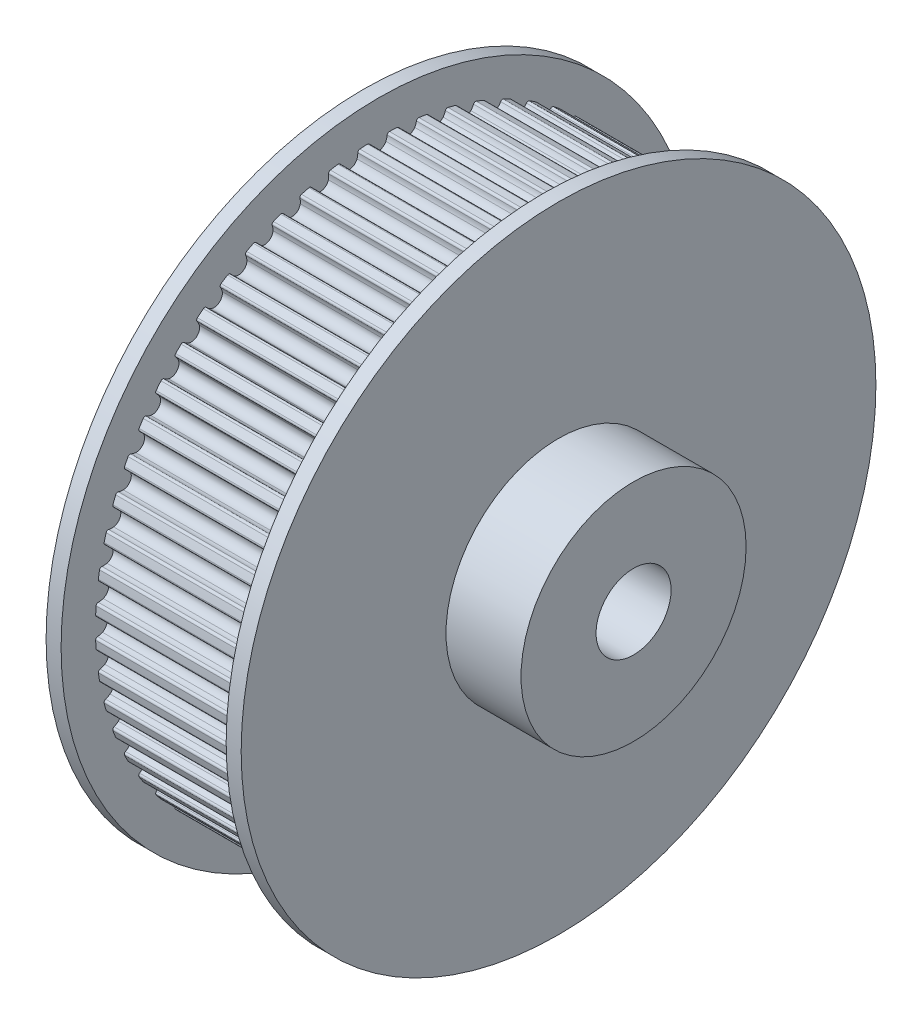
from build123d import *

# Parameters (mm, degrees)
SKETCH1_R           = 5
BOSS_EXTRUDE1_DEPTH = 11
SKETCH2_R           = 5
SKETCH2_R_2         = 2.5
BOSS_EXTRUDE2_DEPTH = 11
SKETCH3_R           = 21.15
SKETCH3_R_2         = 2.5
BOSS_EXTRUDE3_DEPTH = 1
SKETCH4_R           = 21.15
SKETCH4_R_2         = 2.5
BOSS_EXTRUDE4_DEPTH = 1
SKETCH5_R           = 7.5
SKETCH5_R_2         = 2.5
BOSS_EXTRUDE5_DEPTH = 5


with BuildPart() as part:
    # Sketch1 → Boss-Extrude1 (new body)
    with BuildSketch(Plane(origin=(0, 0, 0), x_dir=(0, 0, -1), z_dir=(1, 0, 0))):
        with BuildLine():
            ThreePointArc((37.94444628, 18.368252698), (37.907163031, 18.467222058), (37.813847158, 18.51699276))
            ThreePointArc((37.813847158, 18.51699276), (37.64832341, 18.545935993), (37.489982797, 18.60218608))
            ThreePointArc((37.489982797, 18.60218608), (37.266075143, 18.806812404), (37.183186342, 19.098593171))
            ThreePointArc((37.183186342, 19.098593171), (37.266075143, 19.390373938), (37.489982797, 19.595000262))
            ThreePointArc((37.489982797, 19.595000262), (37.64832341, 19.651250349), (37.813847158, 19.680193582))
            ThreePointArc((37.813847158, 19.680193582), (37.907163031, 19.729964284), (37.94444628, 19.828933644))
            ThreePointArc((37.94444628, 19.828933644), (37.932747007, 20.085649348), (37.917548092, 20.342181644))
            ThreePointArc((37.917548092, 20.342181644), (37.870123969, 20.436711679), (37.772116836, 20.476455567))
            ThreePointArc((37.772116836, 20.476455567), (37.604474452, 20.487938303), (37.44112151, 20.527329145))
            ThreePointArc((37.44112151, 20.527329145), (37.197051171, 20.707429781), (37.084117048, 20.988947904))
            ThreePointArc((37.084117048, 20.988947904), (37.136052381, 21.287794505), (37.337344169, 21.514704587))
            ThreePointArc((37.337344169, 21.514704587), (37.488937641, 21.587197631), (37.650529241, 21.633284253))
            ThreePointArc((37.650529241, 21.633284253), (37.738131465, 21.692536471), (37.764865358, 21.794860827))
            ThreePointArc((37.764865358, 21.794860827), (37.726396076, 22.048947309), (37.684465496, 22.302485575))
            ThreePointArc((37.684465496, 22.302485575), (37.627420088, 22.391540593), (37.52579548, 22.420822225))
            ThreePointArc((37.52579548, 22.420822225), (37.357871186, 22.414718657), (37.191295645, 22.43681868))
            ThreePointArc((37.191295645, 22.43681868), (36.929736706, 22.590420408), (36.787994592, 22.858591515))
            ThreePointArc((36.787994592, 22.858591515), (36.808407441, 23.161229723), (36.98487797, 23.40793749))
            ThreePointArc((36.98487797, 23.40793749), (37.12806341, 23.495879241), (37.283952431, 23.558604318))
            ThreePointArc((37.283952431, 23.558604318), (37.364881217, 23.626688872), (37.380772851, 23.731247137))
            ThreePointArc((37.380772851, 23.731247137), (37.315955039, 23.979920572), (37.247752194, 24.227686989))
            ThreePointArc((37.247752194, 24.227686989), (37.181710502, 24.310291286), (37.07758184, 24.328789846))
            ThreePointArc((37.07758184, 24.328789846), (36.91121545, 24.305166846), (36.743242345, 24.309733917))
            ThreePointArc((36.743242345, 24.309733917), (36.467060501, 24.435153845), (36.298063351, 24.687039797))
            ThreePointArc((36.298063351, 24.687039797), (36.28673007, 24.990153845), (36.436445891, 25.253956314))
            ThreePointArc((36.436445891, 25.253956314), (36.56965453, 25.356383266), (36.718133018, 25.435059568))
            ThreePointArc((36.718133018, 25.435059568), (36.791501695, 25.511230509), (36.796376958, 25.616877121))
            ThreePointArc((36.796376958, 25.616877121), (36.705920773, 25.85741299), (36.612192907, 26.096692979))
            ThreePointArc((36.612192907, 26.096692979), (36.537878498, 26.171941524), (36.432386638, 26.179454338))
            ThreePointArc((36.432386638, 26.179454338), (36.269400896, 26.138570724), (36.101870577, 26.125554806))
            ThreePointArc((36.101870577, 26.125554806), (35.814091733, 26.221418807), (35.619691116, 26.454259889))
            ThreePointArc((35.619691116, 26.454259889), (35.576735874, 26.754528796), (35.698056669, 27.032535692))
            ThreePointArc((35.698056669, 27.032535692), (35.819829046, 27.148325632), (35.959270241, 27.242091166))
            ThreePointArc((35.959270241, 27.242091166), (36.024274964, 27.325513949), (36.018080442, 27.431091422))
            ThreePointArc((36.018080442, 27.431091422), (35.902976941, 27.660854365), (35.784750956, 27.889026323))
            ThreePointArc((35.784750956, 27.889026323), (35.702978035, 27.956094678), (35.597278768, 27.952539434))
            ThreePointArc((35.597278768, 27.952539434), (35.43945938, 27.894843135), (35.274207343, 27.864386832))
            ThreePointArc((35.274207343, 27.864386832), (34.977984466, 27.9296446), (34.760310274, 28.140889757))
            ThreePointArc((34.760310274, 28.140889757), (34.686203698, 28.435023714), (34.777800252, 28.724189135))
            ThreePointArc((34.777800252, 28.724189135), (34.886802202, 28.852073446), (35.015678356, 28.959900895))
            ThreePointArc((35.015678356, 28.959900895), (35.071606922, 29.049661524), (35.054410483, 29.154013129))
            ThreePointArc((35.054410483, 29.154013129), (34.915920763, 29.370485814), (34.774491969, 29.585049841))
            ThreePointArc((34.774491969, 29.585049841), (34.686156456, 29.643203191), (34.581407845, 29.628618841))
            ThreePointArc((34.581407845, 29.628618841), (34.430483914, 29.554741991), (34.269320695, 29.507178989))
            ThreePointArc((34.269320695, 29.507178989), (33.967899264, 29.541115546), (33.729336383, 29.728450331))
            ThreePointArc((33.729336383, 29.728450331), (33.6248904, 30.013226745), (33.685759161, 30.310382535))
            ThreePointArc((33.685759161, 30.310382535), (33.780796437, 30.448960088), (33.897695556, 30.569668074))
            ThreePointArc((33.897695556, 30.569668074), (33.943935198, 30.664783112), (33.915925251, 30.76676555))
            ThreePointArc((33.915925251, 30.76676555), (33.755566635, 30.967576257), (33.592484554, 31.166181546))
            ThreePointArc((33.592484554, 31.166181546), (33.498554273, 31.21478275), (33.395903965, 31.189329083))
            ThreePointArc((33.395903965, 31.189329083), (33.253529044, 31.100081092), (33.098220382, 31.035932502))
            ThreePointArc((33.098220382, 31.035932502), (32.794902832, 31.038176032), (32.538065007, 31.199547965))
            ThreePointArc((32.538065007, 31.199547965), (32.404423949, 31.471846767), (32.433898027, 31.773737224))
            ThreePointArc((32.433898027, 31.773737224), (32.51392938, 31.921489735), (32.617570693, 32.053755756))
            ThreePointArc((32.617570693, 32.053755756), (32.653614801, 32.153183102), (32.615098227, 32.251679033))
            ThreePointArc((32.615098227, 32.251679033), (32.434627638, 32.434627638), (32.251679033, 32.615098227))
            ThreePointArc((32.251679033, 32.615098227), (32.153183102, 32.653614801), (32.053755756, 32.617570693))
            ThreePointArc((32.053755756, 32.617570693), (31.921489735, 32.51392938), (31.773737224, 32.433898027))
            ThreePointArc((31.773737224, 32.433898027), (31.471846767, 32.404423949), (31.199547965, 32.538065007))
            ThreePointArc((31.199547965, 32.538065007), (31.038176032, 32.794902832), (31.035932502, 33.098220382))
            ThreePointArc((31.035932502, 33.098220382), (31.100081092, 33.253529044), (31.189329083, 33.395903965))
            ThreePointArc((31.189329083, 33.395903965), (31.21478275, 33.498554273), (31.166181546, 33.592484554))
            ThreePointArc((31.166181546, 33.592484554), (30.967576257, 33.755566635), (30.76676555, 33.915925251))
            ThreePointArc((30.76676555, 33.915925251), (30.664783112, 33.943935198), (30.569668074, 33.897695556))
            ThreePointArc((30.569668074, 33.897695556), (30.448960088, 33.780796437), (30.310382535, 33.685759161))
            ThreePointArc((30.310382535, 33.685759161), (30.013226745, 33.6248904), (29.728450331, 33.729336383))
            ThreePointArc((29.728450331, 33.729336383), (29.541115546, 33.967899264), (29.507178989, 34.269320695))
            ThreePointArc((29.507178989, 34.269320695), (29.554741991, 34.430483914), (29.628618841, 34.581407845))
            ThreePointArc((29.628618841, 34.581407845), (29.643203191, 34.686156456), (29.585049841, 34.774491969))
            ThreePointArc((29.585049841, 34.774491969), (29.370485814, 34.915920763), (29.154013129, 35.054410483))
            ThreePointArc((29.154013129, 35.054410483), (29.049661524, 35.071606922), (28.959900895, 35.015678356))
            ThreePointArc((28.959900895, 35.015678356), (28.852073446, 34.886802202), (28.724189135, 34.777800252))
            ThreePointArc((28.724189135, 34.777800252), (28.435023714, 34.686203698), (28.140889757, 34.760310274))
            ThreePointArc((28.140889757, 34.760310274), (27.9296446, 34.977984466), (27.864386832, 35.274207343))
            ThreePointArc((27.864386832, 35.274207343), (27.894843135, 35.43945938), (27.952539434, 35.597278768))
            ThreePointArc((27.952539434, 35.597278768), (27.956094678, 35.702978035), (27.889026323, 35.784750956))
            ThreePointArc((27.889026323, 35.784750956), (27.660854365, 35.902976941), (27.431091422, 36.018080442))
            ThreePointArc((27.431091422, 36.018080442), (27.325513949, 36.024274964), (27.242091166, 35.959270241))
            ThreePointArc((27.242091166, 35.959270241), (27.148325632, 35.819829046), (27.032535692, 35.698056669))
            ThreePointArc((27.032535692, 35.698056669), (26.754528796, 35.576735874), (26.454259889, 35.619691116))
            ThreePointArc((26.454259889, 35.619691116), (26.221418807, 35.814091733), (26.125554806, 36.101870577))
            ThreePointArc((26.125554806, 36.101870577), (26.138570724, 36.269400896), (26.179454338, 36.432386638))
            ThreePointArc((26.179454338, 36.432386638), (26.171941524, 36.537878498), (26.096692979, 36.612192907))
            ThreePointArc((26.096692979, 36.612192907), (25.85741299, 36.705920773), (25.616877121, 36.796376958))
            ThreePointArc((25.616877121, 36.796376958), (25.511230509, 36.791501695), (25.435059568, 36.718133018))
            ThreePointArc((25.435059568, 36.718133018), (25.356383266, 36.56965453), (25.253956314, 36.436445891))
            ThreePointArc((25.253956314, 36.436445891), (24.990153845, 36.28673007), (24.687039797, 36.298063351))
            ThreePointArc((24.687039797, 36.298063351), (24.435153845, 36.467060501), (24.309733917, 36.743242345))
            ThreePointArc((24.309733917, 36.743242345), (24.305166846, 36.91121545), (24.328789846, 37.07758184))
            ThreePointArc((24.328789846, 37.07758184), (24.310291286, 37.181710502), (24.227686989, 37.247752194))
            ThreePointArc((24.227686989, 37.247752194), (23.979920572, 37.315955039), (23.731247137, 37.380772851))
            ThreePointArc((23.731247137, 37.380772851), (23.626688872, 37.364881217), (23.558604318, 37.283952431))
            ThreePointArc((23.558604318, 37.283952431), (23.495879241, 37.12806341), (23.40793749, 36.98487797))
            ThreePointArc((23.40793749, 36.98487797), (23.161229723, 36.808407441), (22.858591515, 36.787994592))
            ThreePointArc((22.858591515, 36.787994592), (22.590420408, 36.929736706), (22.43681868, 37.191295645))
            ThreePointArc((22.43681868, 37.191295645), (22.414718657, 37.357871186), (22.420822225, 37.52579548))
            ThreePointArc((22.420822225, 37.52579548), (22.391540593, 37.627420088), (22.302485575, 37.684465496))
            ThreePointArc((22.302485575, 37.684465496), (22.048947309, 37.726396076), (21.794860827, 37.764865358))
            ThreePointArc((21.794860827, 37.764865358), (21.692536471, 37.738131465), (21.633284253, 37.650529241))
            ThreePointArc((21.633284253, 37.650529241), (21.587197631, 37.488937641), (21.514704587, 37.337344169))
            ThreePointArc((21.514704587, 37.337344169), (21.287794505, 37.136052381), (20.988947904, 37.084117048))
            ThreePointArc((20.988947904, 37.084117048), (20.707429781, 37.197051171), (20.527329145, 37.44112151))
            ThreePointArc((20.527329145, 37.44112151), (20.487938303, 37.604474452), (20.476455567, 37.772116836))
            ThreePointArc((20.476455567, 37.772116836), (20.436711679, 37.870123969), (20.342181644, 37.917548092))
            ThreePointArc((20.342181644, 37.917548092), (20.085649348, 37.932747007), (19.828933644, 37.94444628))
            ThreePointArc((19.828933644, 37.94444628), (19.729964284, 37.907163031), (19.680193582, 37.813847158))
            ThreePointArc((19.680193582, 37.813847158), (19.651250349, 37.64832341), (19.595000262, 37.489982797))
            ThreePointArc((19.595000262, 37.489982797), (19.390373938, 37.266075143), (19.098593171, 37.183186342))
            ThreePointArc((19.098593171, 37.183186342), (18.806812404, 37.266075143), (18.60218608, 37.489982797))
            ThreePointArc((18.60218608, 37.489982797), (18.545935993, 37.64832341), (18.51699276, 37.813847158))
            ThreePointArc((18.51699276, 37.813847158), (18.467222058, 37.907163031), (18.368252698, 37.94444628))
            ThreePointArc((18.368252698, 37.94444628), (18.111536994, 37.932747007), (17.855004698, 37.917548092))
            ThreePointArc((17.855004698, 37.917548092), (17.760474663, 37.870123969), (17.720730775, 37.772116836))
            ThreePointArc((17.720730775, 37.772116836), (17.709248039, 37.604474452), (17.669857197, 37.44112151))
            ThreePointArc((17.669857197, 37.44112151), (17.489756561, 37.197051171), (17.208238438, 37.084117048))
            ThreePointArc((17.208238438, 37.084117048), (16.909391837, 37.136052381), (16.682481755, 37.337344169))
            ThreePointArc((16.682481755, 37.337344169), (16.609988711, 37.488937641), (16.563902089, 37.650529241))
            ThreePointArc((16.563902089, 37.650529241), (16.504649871, 37.738131465), (16.402325515, 37.764865358))
            ThreePointArc((16.402325515, 37.764865358), (16.148239033, 37.726396076), (15.894700767, 37.684465496))
            ThreePointArc((15.894700767, 37.684465496), (15.805645749, 37.627420088), (15.776364117, 37.52579548))
            ThreePointArc((15.776364117, 37.52579548), (15.782467685, 37.357871186), (15.760367663, 37.191295645))
            ThreePointArc((15.760367663, 37.191295645), (15.606765934, 36.929736706), (15.338594827, 36.787994592))
            ThreePointArc((15.338594827, 36.787994592), (15.035956619, 36.808407441), (14.789248852, 36.98487797))
            ThreePointArc((14.789248852, 36.98487797), (14.701307101, 37.12806341), (14.638582024, 37.283952431))
            ThreePointArc((14.638582024, 37.283952431), (14.57049747, 37.364881217), (14.465939205, 37.380772851))
            ThreePointArc((14.465939205, 37.380772851), (14.21726577, 37.315955039), (13.969499353, 37.247752194))
            ThreePointArc((13.969499353, 37.247752194), (13.886895056, 37.181710502), (13.868396496, 37.07758184))
            ThreePointArc((13.868396496, 37.07758184), (13.892019496, 36.91121545), (13.887452425, 36.743242345))
            ThreePointArc((13.887452425, 36.743242345), (13.762032497, 36.467060501), (13.510146545, 36.298063351))
            ThreePointArc((13.510146545, 36.298063351), (13.207032497, 36.28673007), (12.943230028, 36.436445891))
            ThreePointArc((12.943230028, 36.436445891), (12.840803076, 36.56965453), (12.762126774, 36.718133018))
            ThreePointArc((12.762126774, 36.718133018), (12.685955833, 36.791501695), (12.580309221, 36.796376958))
            ThreePointArc((12.580309221, 36.796376958), (12.339773352, 36.705920773), (12.100493363, 36.612192907))
            ThreePointArc((12.100493363, 36.612192907), (12.025244818, 36.537878498), (12.017732004, 36.432386638))
            ThreePointArc((12.017732004, 36.432386638), (12.058615618, 36.269400896), (12.071631536, 36.101870577))
            ThreePointArc((12.071631536, 36.101870577), (11.975767535, 35.814091733), (11.742926453, 35.619691116))
            ThreePointArc((11.742926453, 35.619691116), (11.442657546, 35.576735874), (11.16465065, 35.698056669))
            ThreePointArc((11.16465065, 35.698056669), (11.04886071, 35.819829046), (10.955095176, 35.959270241))
            ThreePointArc((10.955095176, 35.959270241), (10.871672393, 36.024274964), (10.76609492, 36.018080442))
            ThreePointArc((10.76609492, 36.018080442), (10.536331977, 35.902976941), (10.308160019, 35.784750956))
            ThreePointArc((10.308160019, 35.784750956), (10.241091664, 35.702978035), (10.244646908, 35.597278768))
            ThreePointArc((10.244646908, 35.597278768), (10.302343207, 35.43945938), (10.33279951, 35.274207343))
            ThreePointArc((10.33279951, 35.274207343), (10.267541742, 34.977984466), (10.056296586, 34.760310274))
            ThreePointArc((10.056296586, 34.760310274), (9.762162628, 34.686203698), (9.472997207, 34.777800252))
            ThreePointArc((9.472997207, 34.777800252), (9.345112896, 34.886802202), (9.237285447, 35.015678356))
            ThreePointArc((9.237285447, 35.015678356), (9.147524818, 35.071606922), (9.043173213, 35.054410483))
            ThreePointArc((9.043173213, 35.054410483), (8.826700529, 34.915920763), (8.612136501, 34.774491969))
            ThreePointArc((8.612136501, 34.774491969), (8.553983151, 34.686156456), (8.568567501, 34.581407845))
            ThreePointArc((8.568567501, 34.581407845), (8.642444351, 34.430483914), (8.690007353, 34.269320695))
            ThreePointArc((8.690007353, 34.269320695), (8.656070796, 33.967899264), (8.468736011, 33.729336383))
            ThreePointArc((8.468736011, 33.729336383), (8.183959597, 33.6248904), (7.886803807, 33.685759161))
            ThreePointArc((7.886803807, 33.685759161), (7.748226254, 33.780796437), (7.627518268, 33.897695556))
            ThreePointArc((7.627518268, 33.897695556), (7.532403231, 33.943935198), (7.430420792, 33.915925251))
            ThreePointArc((7.430420792, 33.915925251), (7.229610085, 33.755566635), (7.031004796, 33.592484554))
            ThreePointArc((7.031004796, 33.592484554), (6.982403592, 33.498554273), (7.007857259, 33.395903965))
            ThreePointArc((7.007857259, 33.395903965), (7.09710525, 33.253529044), (7.16125384, 33.098220382))
            ThreePointArc((7.16125384, 33.098220382), (7.15901031, 32.794902832), (6.997638377, 32.538065007))
            ThreePointArc((6.997638377, 32.538065007), (6.725339575, 32.404423949), (6.423449118, 32.433898027))
            ThreePointArc((6.423449118, 32.433898027), (6.275696607, 32.51392938), (6.143430587, 32.617570693))
            ThreePointArc((6.143430587, 32.617570693), (6.04400324, 32.653614801), (5.945507309, 32.615098227))
            ThreePointArc((5.945507309, 32.615098227), (5.762558704, 32.434627638), (5.582088115, 32.251679033))
            ThreePointArc((5.582088115, 32.251679033), (5.543571541, 32.153183102), (5.579615649, 32.053755756))
            ThreePointArc((5.579615649, 32.053755756), (5.683256962, 31.921489735), (5.763288315, 31.773737224))
            ThreePointArc((5.763288315, 31.773737224), (5.792762393, 31.471846767), (5.659121335, 31.199547965))
            ThreePointArc((5.659121335, 31.199547965), (5.40228351, 31.038176032), (5.09896596, 31.035932502))
            ThreePointArc((5.09896596, 31.035932502), (4.943657298, 31.100081092), (4.801282377, 31.189329083))
            ThreePointArc((4.801282377, 31.189329083), (4.698632069, 31.21478275), (4.604701788, 31.166181546))
            ThreePointArc((4.604701788, 31.166181546), (4.441619707, 30.967576257), (4.281261091, 30.76676555))
            ThreePointArc((4.281261091, 30.76676555), (4.253251144, 30.664783112), (4.299490786, 30.569668074))
            ThreePointArc((4.299490786, 30.569668074), (4.416389905, 30.448960088), (4.511427181, 30.310382535))
            ThreePointArc((4.511427181, 30.310382535), (4.572295942, 30.013226745), (4.467849959, 29.728450331))
            ThreePointArc((4.467849959, 29.728450331), (4.229287078, 29.541115546), (3.927865647, 29.507178989))
            ThreePointArc((3.927865647, 29.507178989), (3.766702428, 29.554741991), (3.615778497, 29.628618841))
            ThreePointArc((3.615778497, 29.628618841), (3.511029886, 29.643203191), (3.422694373, 29.585049841))
            ThreePointArc((3.422694373, 29.585049841), (3.281265579, 29.370485814), (3.142775859, 29.154013129))
            ThreePointArc((3.142775859, 29.154013129), (3.12557942, 29.049661524), (3.181507986, 28.959900895))
            ThreePointArc((3.181507986, 28.959900895), (3.31038414, 28.852073446), (3.41938609, 28.724189135))
            ThreePointArc((3.41938609, 28.724189135), (3.510982644, 28.435023714), (3.436876068, 28.140889757))
            ThreePointArc((3.436876068, 28.140889757), (3.219201877, 27.9296446), (2.922978999, 27.864386832))
            ThreePointArc((2.922978999, 27.864386832), (2.757726962, 27.894843135), (2.599907574, 27.952539434))
            ThreePointArc((2.599907574, 27.952539434), (2.494208307, 27.956094678), (2.412435386, 27.889026323))
            ThreePointArc((2.412435386, 27.889026323), (2.294209402, 27.660854365), (2.1791059, 27.431091422))
            ThreePointArc((2.1791059, 27.431091422), (2.172911378, 27.325513949), (2.237916101, 27.242091166))
            ThreePointArc((2.237916101, 27.242091166), (2.377357296, 27.148325632), (2.499129673, 27.032535692))
            ThreePointArc((2.499129673, 27.032535692), (2.620450468, 26.754528796), (2.577495226, 26.454259889))
            ThreePointArc((2.577495226, 26.454259889), (2.383094609, 26.221418807), (2.095315765, 26.125554806))
            ThreePointArc((2.095315765, 26.125554806), (1.927785446, 26.138570724), (1.764799704, 26.179454338))
            ThreePointArc((1.764799704, 26.179454338), (1.659307844, 26.171941524), (1.584993435, 26.096692979))
            ThreePointArc((1.584993435, 26.096692979), (1.491265569, 25.85741299), (1.400809384, 25.616877121))
            ThreePointArc((1.400809384, 25.616877121), (1.405684647, 25.511230509), (1.479053324, 25.435059568))
            ThreePointArc((1.479053324, 25.435059568), (1.627531812, 25.356383266), (1.760740451, 25.253956314))
            ThreePointArc((1.760740451, 25.253956314), (1.910456272, 24.990153845), (1.899122991, 24.687039797))
            ThreePointArc((1.899122991, 24.687039797), (1.730125841, 24.435153845), (1.453943997, 24.309733917))
            ThreePointArc((1.453943997, 24.309733917), (1.285970892, 24.305166846), (1.119604502, 24.328789846))
            ThreePointArc((1.119604502, 24.328789846), (1.01547584, 24.310291286), (0.949434148, 24.227686989))
            ThreePointArc((0.949434148, 24.227686989), (0.881231303, 23.979920572), (0.816413491, 23.731247137))
            ThreePointArc((0.816413491, 23.731247137), (0.832305125, 23.626688872), (0.913233911, 23.558604318))
            ThreePointArc((0.913233911, 23.558604318), (1.069122932, 23.495879241), (1.212308372, 23.40793749))
            ThreePointArc((1.212308372, 23.40793749), (1.388778901, 23.161229723), (1.409191751, 22.858591515))
            ThreePointArc((1.409191751, 22.858591515), (1.267449636, 22.590420408), (1.005890697, 22.43681868))
            ThreePointArc((1.005890697, 22.43681868), (0.839315156, 22.414718657), (0.671390862, 22.420822225))
            ThreePointArc((0.671390862, 22.420822225), (0.569766254, 22.391540593), (0.512720846, 22.302485575))
            ThreePointArc((0.512720846, 22.302485575), (0.470790266, 22.048947309), (0.432320984, 21.794860827))
            ThreePointArc((0.432320984, 21.794860827), (0.459054877, 21.692536471), (0.546657101, 21.633284253))
            ThreePointArc((0.546657101, 21.633284253), (0.708248701, 21.587197631), (0.859842173, 21.514704587))
            ThreePointArc((0.859842173, 21.514704587), (1.061133961, 21.287794505), (1.113069294, 20.988947904))
            ThreePointArc((1.113069294, 20.988947904), (1.000135171, 20.707429781), (0.756064832, 20.527329145))
            ThreePointArc((0.756064832, 20.527329145), (0.59271189, 20.487938303), (0.425069506, 20.476455567))
            ThreePointArc((0.425069506, 20.476455567), (0.327062373, 20.436711679), (0.27963825, 20.342181644))
            ThreePointArc((0.27963825, 20.342181644), (0.264439335, 20.085649348), (0.252740062, 19.828933644))
            ThreePointArc((0.252740062, 19.828933644), (0.290023311, 19.729964284), (0.383339184, 19.680193582))
            ThreePointArc((0.383339184, 19.680193582), (0.548862932, 19.651250349), (0.707203546, 19.595000262))
            ThreePointArc((0.707203546, 19.595000262), (0.931111199, 19.390373938), (1.014, 19.098593171))
            ThreePointArc((1.014, 19.098593171), (0.931111199, 18.806812404), (0.707203546, 18.60218608))
            ThreePointArc((0.707203546, 18.60218608), (0.548862932, 18.545935993), (0.383339184, 18.51699276))
            ThreePointArc((0.383339184, 18.51699276), (0.290023311, 18.467222058), (0.252740062, 18.368252698))
            ThreePointArc((0.252740062, 18.368252698), (0.264439335, 18.111536994), (0.27963825, 17.855004698))
            ThreePointArc((0.27963825, 17.855004698), (0.327062373, 17.760474663), (0.425069506, 17.720730775))
            ThreePointArc((0.425069506, 17.720730775), (0.59271189, 17.709248039), (0.756064832, 17.669857197))
            ThreePointArc((0.756064832, 17.669857197), (1.000135171, 17.489756561), (1.113069294, 17.208238438))
            ThreePointArc((1.113069294, 17.208238438), (1.061133961, 16.909391837), (0.859842173, 16.682481755))
            ThreePointArc((0.859842173, 16.682481755), (0.708248701, 16.609988711), (0.546657101, 16.563902089))
            ThreePointArc((0.546657101, 16.563902089), (0.459054877, 16.504649871), (0.432320984, 16.402325515))
            ThreePointArc((0.432320984, 16.402325515), (0.470790266, 16.148239033), (0.512720846, 15.894700767))
            ThreePointArc((0.512720846, 15.894700767), (0.569766254, 15.805645749), (0.671390862, 15.776364117))
            ThreePointArc((0.671390862, 15.776364117), (0.839315156, 15.782467685), (1.005890697, 15.760367663))
            ThreePointArc((1.005890697, 15.760367663), (1.267449636, 15.606765934), (1.409191751, 15.338594827))
            ThreePointArc((1.409191751, 15.338594827), (1.388778901, 15.035956619), (1.212308372, 14.789248852))
            ThreePointArc((1.212308372, 14.789248852), (1.069122932, 14.701307101), (0.913233911, 14.638582024))
            ThreePointArc((0.913233911, 14.638582024), (0.832305125, 14.57049747), (0.816413491, 14.465939205))
            ThreePointArc((0.816413491, 14.465939205), (0.881231303, 14.21726577), (0.949434148, 13.969499353))
            ThreePointArc((0.949434148, 13.969499353), (1.01547584, 13.886895056), (1.119604502, 13.868396496))
            ThreePointArc((1.119604502, 13.868396496), (1.285970892, 13.892019496), (1.453943997, 13.887452425))
            ThreePointArc((1.453943997, 13.887452425), (1.730125841, 13.762032497), (1.899122991, 13.510146545))
            ThreePointArc((1.899122991, 13.510146545), (1.910456272, 13.207032497), (1.760740451, 12.943230028))
            ThreePointArc((1.760740451, 12.943230028), (1.627531812, 12.840803076), (1.479053324, 12.762126774))
            ThreePointArc((1.479053324, 12.762126774), (1.405684647, 12.685955833), (1.400809384, 12.580309221))
            ThreePointArc((1.400809384, 12.580309221), (1.491265569, 12.339773352), (1.584993435, 12.100493363))
            ThreePointArc((1.584993435, 12.100493363), (1.659307844, 12.025244818), (1.764799704, 12.017732004))
            ThreePointArc((1.764799704, 12.017732004), (1.927785446, 12.058615618), (2.095315765, 12.071631536))
            ThreePointArc((2.095315765, 12.071631536), (2.383094609, 11.975767535), (2.577495226, 11.742926453))
            ThreePointArc((2.577495226, 11.742926453), (2.620450468, 11.442657546), (2.499129673, 11.16465065))
            ThreePointArc((2.499129673, 11.16465065), (2.377357296, 11.04886071), (2.237916101, 10.955095176))
            ThreePointArc((2.237916101, 10.955095176), (2.172911378, 10.871672393), (2.1791059, 10.76609492))
            ThreePointArc((2.1791059, 10.76609492), (2.294209402, 10.536331977), (2.412435386, 10.308160019))
            ThreePointArc((2.412435386, 10.308160019), (2.494208307, 10.241091664), (2.599907574, 10.244646908))
            ThreePointArc((2.599907574, 10.244646908), (2.757726962, 10.302343207), (2.922978999, 10.33279951))
            ThreePointArc((2.922978999, 10.33279951), (3.219201877, 10.267541742), (3.436876068, 10.056296586))
            ThreePointArc((3.436876068, 10.056296586), (3.510982644, 9.762162628), (3.41938609, 9.472997207))
            ThreePointArc((3.41938609, 9.472997207), (3.31038414, 9.345112896), (3.181507986, 9.237285447))
            ThreePointArc((3.181507986, 9.237285447), (3.12557942, 9.147524818), (3.142775859, 9.043173213))
            ThreePointArc((3.142775859, 9.043173213), (3.281265579, 8.826700529), (3.422694373, 8.612136501))
            ThreePointArc((3.422694373, 8.612136501), (3.511029886, 8.553983151), (3.615778497, 8.568567501))
            ThreePointArc((3.615778497, 8.568567501), (3.766702428, 8.642444351), (3.927865647, 8.690007353))
            ThreePointArc((3.927865647, 8.690007353), (4.229287078, 8.656070796), (4.467849959, 8.468736011))
            ThreePointArc((4.467849959, 8.468736011), (4.572295942, 8.183959597), (4.511427181, 7.886803807))
            ThreePointArc((4.511427181, 7.886803807), (4.416389905, 7.748226254), (4.299490786, 7.627518268))
            ThreePointArc((4.299490786, 7.627518268), (4.253251144, 7.532403231), (4.281261091, 7.430420792))
            ThreePointArc((4.281261091, 7.430420792), (4.441619707, 7.229610085), (4.604701788, 7.031004796))
            ThreePointArc((4.604701788, 7.031004796), (4.698632069, 6.982403592), (4.801282377, 7.007857259))
            ThreePointArc((4.801282377, 7.007857259), (4.943657298, 7.09710525), (5.09896596, 7.16125384))
            ThreePointArc((5.09896596, 7.16125384), (5.40228351, 7.15901031), (5.659121335, 6.997638377))
            ThreePointArc((5.659121335, 6.997638377), (5.792762393, 6.725339575), (5.763288315, 6.423449118))
            ThreePointArc((5.763288315, 6.423449118), (5.683256962, 6.275696607), (5.579615649, 6.143430587))
            ThreePointArc((5.579615649, 6.143430587), (5.543571541, 6.04400324), (5.582088115, 5.945507309))
            ThreePointArc((5.582088115, 5.945507309), (5.762558704, 5.762558704), (5.945507309, 5.582088115))
            ThreePointArc((5.945507309, 5.582088115), (6.04400324, 5.543571541), (6.143430587, 5.579615649))
            ThreePointArc((6.143430587, 5.579615649), (6.275696607, 5.683256962), (6.423449118, 5.763288315))
            ThreePointArc((6.423449118, 5.763288315), (6.725339575, 5.792762393), (6.997638377, 5.659121335))
            ThreePointArc((6.997638377, 5.659121335), (7.15901031, 5.40228351), (7.16125384, 5.09896596))
            ThreePointArc((7.16125384, 5.09896596), (7.09710525, 4.943657298), (7.007857259, 4.801282377))
            ThreePointArc((7.007857259, 4.801282377), (6.982403592, 4.698632069), (7.031004796, 4.604701788))
            ThreePointArc((7.031004796, 4.604701788), (7.229610085, 4.441619707), (7.430420792, 4.281261091))
            ThreePointArc((7.430420792, 4.281261091), (7.532403231, 4.253251144), (7.627518268, 4.299490786))
            ThreePointArc((7.627518268, 4.299490786), (7.748226254, 4.416389905), (7.886803807, 4.511427181))
            ThreePointArc((7.886803807, 4.511427181), (8.183959597, 4.572295942), (8.468736011, 4.467849959))
            ThreePointArc((8.468736011, 4.467849959), (8.656070796, 4.229287078), (8.690007353, 3.927865647))
            ThreePointArc((8.690007353, 3.927865647), (8.642444351, 3.766702428), (8.568567501, 3.615778497))
            ThreePointArc((8.568567501, 3.615778497), (8.553983151, 3.511029886), (8.612136501, 3.422694373))
            ThreePointArc((8.612136501, 3.422694373), (8.826700529, 3.281265579), (9.043173213, 3.142775859))
            ThreePointArc((9.043173213, 3.142775859), (9.147524818, 3.12557942), (9.237285447, 3.181507986))
            ThreePointArc((9.237285447, 3.181507986), (9.345112896, 3.31038414), (9.472997207, 3.41938609))
            ThreePointArc((9.472997207, 3.41938609), (9.762162628, 3.510982644), (10.056296586, 3.436876068))
            ThreePointArc((10.056296586, 3.436876068), (10.267541742, 3.219201877), (10.33279951, 2.922978999))
            ThreePointArc((10.33279951, 2.922978999), (10.302343207, 2.757726962), (10.244646908, 2.599907574))
            ThreePointArc((10.244646908, 2.599907574), (10.241091664, 2.494208307), (10.308160019, 2.412435386))
            ThreePointArc((10.308160019, 2.412435386), (10.536331977, 2.294209402), (10.76609492, 2.1791059))
            ThreePointArc((10.76609492, 2.1791059), (10.871672393, 2.172911378), (10.955095176, 2.237916101))
            ThreePointArc((10.955095176, 2.237916101), (11.04886071, 2.377357296), (11.16465065, 2.499129673))
            ThreePointArc((11.16465065, 2.499129673), (11.442657546, 2.620450468), (11.742926453, 2.577495226))
            ThreePointArc((11.742926453, 2.577495226), (11.975767535, 2.383094609), (12.071631536, 2.095315765))
            ThreePointArc((12.071631536, 2.095315765), (12.058615618, 1.927785446), (12.017732004, 1.764799704))
            ThreePointArc((12.017732004, 1.764799704), (12.025244818, 1.659307844), (12.100493363, 1.584993435))
            ThreePointArc((12.100493363, 1.584993435), (12.339773352, 1.491265569), (12.580309221, 1.400809384))
            ThreePointArc((12.580309221, 1.400809384), (12.685955833, 1.405684647), (12.762126774, 1.479053324))
            ThreePointArc((12.762126774, 1.479053324), (12.840803076, 1.627531812), (12.943230028, 1.760740451))
            ThreePointArc((12.943230028, 1.760740451), (13.207032497, 1.910456272), (13.510146545, 1.899122991))
            ThreePointArc((13.510146545, 1.899122991), (13.762032497, 1.730125841), (13.887452425, 1.453943997))
            ThreePointArc((13.887452425, 1.453943997), (13.892019496, 1.285970892), (13.868396496, 1.119604502))
            ThreePointArc((13.868396496, 1.119604502), (13.886895056, 1.01547584), (13.969499353, 0.949434148))
            ThreePointArc((13.969499353, 0.949434148), (14.21726577, 0.881231303), (14.465939205, 0.816413491))
            ThreePointArc((14.465939205, 0.816413491), (14.57049747, 0.832305125), (14.638582024, 0.913233911))
            ThreePointArc((14.638582024, 0.913233911), (14.701307101, 1.069122932), (14.789248852, 1.212308372))
            ThreePointArc((14.789248852, 1.212308372), (15.035956619, 1.388778901), (15.338594827, 1.409191751))
            ThreePointArc((15.338594827, 1.409191751), (15.606765934, 1.267449636), (15.760367663, 1.005890697))
            ThreePointArc((15.760367663, 1.005890697), (15.782467685, 0.839315156), (15.776364117, 0.671390862))
            ThreePointArc((15.776364117, 0.671390862), (15.805645749, 0.569766254), (15.894700767, 0.512720846))
            ThreePointArc((15.894700767, 0.512720846), (16.148239033, 0.470790266), (16.402325515, 0.432320984))
            ThreePointArc((16.402325515, 0.432320984), (16.504649871, 0.459054877), (16.563902089, 0.546657101))
            ThreePointArc((16.563902089, 0.546657101), (16.609988711, 0.708248701), (16.682481755, 0.859842173))
            ThreePointArc((16.682481755, 0.859842173), (16.909391837, 1.061133961), (17.208238438, 1.113069294))
            ThreePointArc((17.208238438, 1.113069294), (17.489756561, 1.000135171), (17.669857197, 0.756064832))
            ThreePointArc((17.669857197, 0.756064832), (17.709248039, 0.59271189), (17.720730775, 0.425069506))
            ThreePointArc((17.720730775, 0.425069506), (17.760474663, 0.327062373), (17.855004698, 0.27963825))
            ThreePointArc((17.855004698, 0.27963825), (18.111536994, 0.264439335), (18.368252698, 0.252740062))
            ThreePointArc((18.368252698, 0.252740062), (18.467222058, 0.290023311), (18.51699276, 0.383339184))
            ThreePointArc((18.51699276, 0.383339184), (18.545935993, 0.548862932), (18.60218608, 0.707203546))
            ThreePointArc((18.60218608, 0.707203546), (18.806812404, 0.931111199), (19.098593171, 1.014))
            ThreePointArc((19.098593171, 1.014), (19.390373938, 0.931111199), (19.595000262, 0.707203546))
            ThreePointArc((19.595000262, 0.707203546), (19.651250349, 0.548862932), (19.680193582, 0.383339184))
            ThreePointArc((19.680193582, 0.383339184), (19.729964284, 0.290023311), (19.828933644, 0.252740062))
            ThreePointArc((19.828933644, 0.252740062), (20.085649348, 0.264439335), (20.342181644, 0.27963825))
            ThreePointArc((20.342181644, 0.27963825), (20.436711679, 0.327062373), (20.476455567, 0.425069506))
            ThreePointArc((20.476455567, 0.425069506), (20.487938303, 0.59271189), (20.527329145, 0.756064832))
            ThreePointArc((20.527329145, 0.756064832), (20.707429781, 1.000135171), (20.988947904, 1.113069294))
            ThreePointArc((20.988947904, 1.113069294), (21.287794505, 1.061133961), (21.514704587, 0.859842173))
            ThreePointArc((21.514704587, 0.859842173), (21.587197631, 0.708248701), (21.633284253, 0.546657101))
            ThreePointArc((21.633284253, 0.546657101), (21.692536471, 0.459054877), (21.794860827, 0.432320984))
            ThreePointArc((21.794860827, 0.432320984), (22.048947309, 0.470790266), (22.302485575, 0.512720846))
            ThreePointArc((22.302485575, 0.512720846), (22.391540593, 0.569766254), (22.420822225, 0.671390862))
            ThreePointArc((22.420822225, 0.671390862), (22.414718657, 0.839315156), (22.43681868, 1.005890697))
            ThreePointArc((22.43681868, 1.005890697), (22.590420408, 1.267449636), (22.858591515, 1.409191751))
            ThreePointArc((22.858591515, 1.409191751), (23.161229723, 1.388778901), (23.40793749, 1.212308372))
            ThreePointArc((23.40793749, 1.212308372), (23.495879241, 1.069122932), (23.558604318, 0.913233911))
            ThreePointArc((23.558604318, 0.913233911), (23.626688872, 0.832305125), (23.731247137, 0.816413491))
            ThreePointArc((23.731247137, 0.816413491), (23.979920572, 0.881231303), (24.227686989, 0.949434148))
            ThreePointArc((24.227686989, 0.949434148), (24.310291286, 1.01547584), (24.328789846, 1.119604502))
            ThreePointArc((24.328789846, 1.119604502), (24.305166846, 1.285970892), (24.309733917, 1.453943997))
            ThreePointArc((24.309733917, 1.453943997), (24.435153845, 1.730125841), (24.687039797, 1.899122991))
            ThreePointArc((24.687039797, 1.899122991), (24.990153845, 1.910456272), (25.253956314, 1.760740451))
            ThreePointArc((25.253956314, 1.760740451), (25.356383266, 1.627531812), (25.435059568, 1.479053324))
            ThreePointArc((25.435059568, 1.479053324), (25.511230509, 1.405684647), (25.616877121, 1.400809384))
            ThreePointArc((25.616877121, 1.400809384), (25.85741299, 1.491265569), (26.096692979, 1.584993435))
            ThreePointArc((26.096692979, 1.584993435), (26.171941524, 1.659307844), (26.179454338, 1.764799704))
            ThreePointArc((26.179454338, 1.764799704), (26.138570724, 1.927785446), (26.125554806, 2.095315765))
            ThreePointArc((26.125554806, 2.095315765), (26.221418807, 2.383094609), (26.454259889, 2.577495226))
            ThreePointArc((26.454259889, 2.577495226), (26.754528796, 2.620450468), (27.032535692, 2.499129673))
            ThreePointArc((27.032535692, 2.499129673), (27.148325632, 2.377357296), (27.242091166, 2.237916101))
            ThreePointArc((27.242091166, 2.237916101), (27.325513949, 2.172911378), (27.431091422, 2.1791059))
            ThreePointArc((27.431091422, 2.1791059), (27.660854365, 2.294209402), (27.889026323, 2.412435386))
            ThreePointArc((27.889026323, 2.412435386), (27.956094678, 2.494208307), (27.952539434, 2.599907574))
            ThreePointArc((27.952539434, 2.599907574), (27.894843135, 2.757726962), (27.864386832, 2.922978999))
            ThreePointArc((27.864386832, 2.922978999), (27.9296446, 3.219201877), (28.140889757, 3.436876068))
            ThreePointArc((28.140889757, 3.436876068), (28.435023714, 3.510982644), (28.724189135, 3.41938609))
            ThreePointArc((28.724189135, 3.41938609), (28.852073446, 3.31038414), (28.959900895, 3.181507986))
            ThreePointArc((28.959900895, 3.181507986), (29.049661524, 3.12557942), (29.154013129, 3.142775859))
            ThreePointArc((29.154013129, 3.142775859), (29.370485814, 3.281265579), (29.585049841, 3.422694373))
            ThreePointArc((29.585049841, 3.422694373), (29.643203191, 3.511029886), (29.628618841, 3.615778497))
            ThreePointArc((29.628618841, 3.615778497), (29.554741991, 3.766702428), (29.507178989, 3.927865647))
            ThreePointArc((29.507178989, 3.927865647), (29.541115546, 4.229287078), (29.728450331, 4.467849959))
            ThreePointArc((29.728450331, 4.467849959), (30.013226745, 4.572295942), (30.310382535, 4.511427181))
            ThreePointArc((30.310382535, 4.511427181), (30.448960088, 4.416389905), (30.569668074, 4.299490786))
            ThreePointArc((30.569668074, 4.299490786), (30.664783112, 4.253251144), (30.76676555, 4.281261091))
            ThreePointArc((30.76676555, 4.281261091), (30.967576257, 4.441619707), (31.166181546, 4.604701788))
            ThreePointArc((31.166181546, 4.604701788), (31.21478275, 4.698632069), (31.189329083, 4.801282377))
            ThreePointArc((31.189329083, 4.801282377), (31.100081092, 4.943657298), (31.035932502, 5.09896596))
            ThreePointArc((31.035932502, 5.09896596), (31.038176032, 5.40228351), (31.199547965, 5.659121335))
            ThreePointArc((31.199547965, 5.659121335), (31.471846767, 5.792762393), (31.773737224, 5.763288315))
            ThreePointArc((31.773737224, 5.763288315), (31.921489735, 5.683256962), (32.053755756, 5.579615649))
            ThreePointArc((32.053755756, 5.579615649), (32.153183102, 5.543571541), (32.251679033, 5.582088115))
            ThreePointArc((32.251679033, 5.582088115), (32.434627638, 5.762558704), (32.615098227, 5.945507309))
            ThreePointArc((32.615098227, 5.945507309), (32.653614801, 6.04400324), (32.617570693, 6.143430587))
            ThreePointArc((32.617570693, 6.143430587), (32.51392938, 6.275696607), (32.433898027, 6.423449118))
            ThreePointArc((32.433898027, 6.423449118), (32.404423949, 6.725339575), (32.538065007, 6.997638377))
            ThreePointArc((32.538065007, 6.997638377), (32.794902832, 7.15901031), (33.098220382, 7.16125384))
            ThreePointArc((33.098220382, 7.16125384), (33.253529044, 7.09710525), (33.395903965, 7.007857259))
            ThreePointArc((33.395903965, 7.007857259), (33.498554273, 6.982403592), (33.592484554, 7.031004796))
            ThreePointArc((33.592484554, 7.031004796), (33.755566635, 7.229610085), (33.915925251, 7.430420792))
            ThreePointArc((33.915925251, 7.430420792), (33.943935198, 7.532403231), (33.897695556, 7.627518268))
            ThreePointArc((33.897695556, 7.627518268), (33.780796437, 7.748226254), (33.685759161, 7.886803807))
            ThreePointArc((33.685759161, 7.886803807), (33.6248904, 8.183959597), (33.729336383, 8.468736011))
            ThreePointArc((33.729336383, 8.468736011), (33.967899264, 8.656070796), (34.269320695, 8.690007353))
            ThreePointArc((34.269320695, 8.690007353), (34.430483914, 8.642444351), (34.581407845, 8.568567501))
            ThreePointArc((34.581407845, 8.568567501), (34.686156456, 8.553983151), (34.774491969, 8.612136501))
            ThreePointArc((34.774491969, 8.612136501), (34.915920763, 8.826700529), (35.054410483, 9.043173213))
            ThreePointArc((35.054410483, 9.043173213), (35.071606922, 9.147524818), (35.015678356, 9.237285447))
            ThreePointArc((35.015678356, 9.237285447), (34.886802202, 9.345112896), (34.777800252, 9.472997207))
            ThreePointArc((34.777800252, 9.472997207), (34.686203698, 9.762162628), (34.760310274, 10.056296586))
            ThreePointArc((34.760310274, 10.056296586), (34.977984466, 10.267541742), (35.274207343, 10.33279951))
            ThreePointArc((35.274207343, 10.33279951), (35.43945938, 10.302343207), (35.597278768, 10.244646908))
            ThreePointArc((35.597278768, 10.244646908), (35.702978035, 10.241091664), (35.784750956, 10.308160019))
            ThreePointArc((35.784750956, 10.308160019), (35.902976941, 10.536331977), (36.018080442, 10.76609492))
            ThreePointArc((36.018080442, 10.76609492), (36.024274964, 10.871672393), (35.959270241, 10.955095176))
            ThreePointArc((35.959270241, 10.955095176), (35.819829046, 11.04886071), (35.698056669, 11.16465065))
            ThreePointArc((35.698056669, 11.16465065), (35.576735874, 11.442657546), (35.619691116, 11.742926453))
            ThreePointArc((35.619691116, 11.742926453), (35.814091733, 11.975767535), (36.101870577, 12.071631536))
            ThreePointArc((36.101870577, 12.071631536), (36.269400896, 12.058615618), (36.432386638, 12.017732004))
            ThreePointArc((36.432386638, 12.017732004), (36.537878498, 12.025244818), (36.612192907, 12.100493363))
            ThreePointArc((36.612192907, 12.100493363), (36.705920773, 12.339773352), (36.796376958, 12.580309221))
            ThreePointArc((36.796376958, 12.580309221), (36.791501695, 12.685955833), (36.718133018, 12.762126774))
            ThreePointArc((36.718133018, 12.762126774), (36.56965453, 12.840803076), (36.436445891, 12.943230028))
            ThreePointArc((36.436445891, 12.943230028), (36.28673007, 13.207032497), (36.298063351, 13.510146545))
            ThreePointArc((36.298063351, 13.510146545), (36.467060501, 13.762032497), (36.743242345, 13.887452425))
            ThreePointArc((36.743242345, 13.887452425), (36.91121545, 13.892019496), (37.07758184, 13.868396496))
            ThreePointArc((37.07758184, 13.868396496), (37.181710502, 13.886895056), (37.247752194, 13.969499353))
            ThreePointArc((37.247752194, 13.969499353), (37.315955039, 14.21726577), (37.380772851, 14.465939205))
            ThreePointArc((37.380772851, 14.465939205), (37.364881217, 14.57049747), (37.283952431, 14.638582024))
            ThreePointArc((37.283952431, 14.638582024), (37.12806341, 14.701307101), (36.98487797, 14.789248852))
            ThreePointArc((36.98487797, 14.789248852), (36.808407441, 15.035956619), (36.787994592, 15.338594827))
            ThreePointArc((36.787994592, 15.338594827), (36.929736706, 15.606765934), (37.191295645, 15.760367663))
            ThreePointArc((37.191295645, 15.760367663), (37.357871186, 15.782467685), (37.52579548, 15.776364117))
            ThreePointArc((37.52579548, 15.776364117), (37.627420088, 15.805645749), (37.684465496, 15.894700767))
            ThreePointArc((37.684465496, 15.894700767), (37.726396076, 16.148239033), (37.764865358, 16.402325515))
            ThreePointArc((37.764865358, 16.402325515), (37.738131465, 16.504649871), (37.650529241, 16.563902089))
            ThreePointArc((37.650529241, 16.563902089), (37.488937641, 16.609988711), (37.337344169, 16.682481755))
            ThreePointArc((37.337344169, 16.682481755), (37.136052381, 16.909391837), (37.084117048, 17.208238438))
            ThreePointArc((37.084117048, 17.208238438), (37.197051171, 17.489756561), (37.44112151, 17.669857197))
            ThreePointArc((37.44112151, 17.669857197), (37.604474452, 17.709248039), (37.772116836, 17.720730775))
            ThreePointArc((37.772116836, 17.720730775), (37.870123969, 17.760474663), (37.917548092, 17.855004698))
            ThreePointArc((37.917548092, 17.855004698), (37.932747007, 18.111536994), (37.94444628, 18.368252698))
        make_face()
        with Locations((19.098593171, 19.098593171)):
            Circle(SKETCH1_R, mode=Mode.SUBTRACT)
    extrude(amount=BOSS_EXTRUDE1_DEPTH)

    # Sketch2 → Boss-Extrude2 (add)
    with BuildSketch(Plane(origin=(11, 0, 0), x_dir=(0, 0, -1), z_dir=(1, 0, 0))):
        with Locations((19.098593171, 19.098593171)):
            Circle(SKETCH2_R)
        with Locations((19.098593171, 19.098593171)):
            Circle(SKETCH2_R_2, mode=Mode.SUBTRACT)
    extrude(amount=-BOSS_EXTRUDE2_DEPTH)

    # Sketch3 → Boss-Extrude3 (add)
    with BuildSketch(Plane.ZY):
        with Locations((-19.098593171, 19.098593171)):
            Circle(SKETCH3_R)
        with Locations(Location((-19.098593171, 19.098593171, 0), (0, 0, 180))):
            Circle(SKETCH3_R_2, mode=Mode.SUBTRACT)
    extrude(amount=BOSS_EXTRUDE3_DEPTH)

    # Sketch4 → Boss-Extrude4 (add)
    with BuildSketch(Plane(origin=(11, 0, 0), x_dir=(0, 0, -1), z_dir=(1, 0, 0))):
        with Locations(Location((19.098593171, 19.098593171, 0), (0, 0, 180))):
            Circle(SKETCH4_R)
        with Locations((19.098593171, 19.098593171)):
            Circle(SKETCH4_R_2, mode=Mode.SUBTRACT)
    extrude(amount=BOSS_EXTRUDE4_DEPTH)

    # Sketch5 → Boss-Extrude5 (add)
    with BuildSketch(Plane(origin=(12, 0, 0), x_dir=(0, 0, -1), z_dir=(1, 0, 0))):
        with Locations((19.098593171, 19.098593171)):
            Circle(SKETCH5_R)
        with Locations((19.098593171, 19.098593171)):
            Circle(SKETCH5_R_2, mode=Mode.SUBTRACT)
    extrude(amount=BOSS_EXTRUDE5_DEPTH)


solid = part.part
